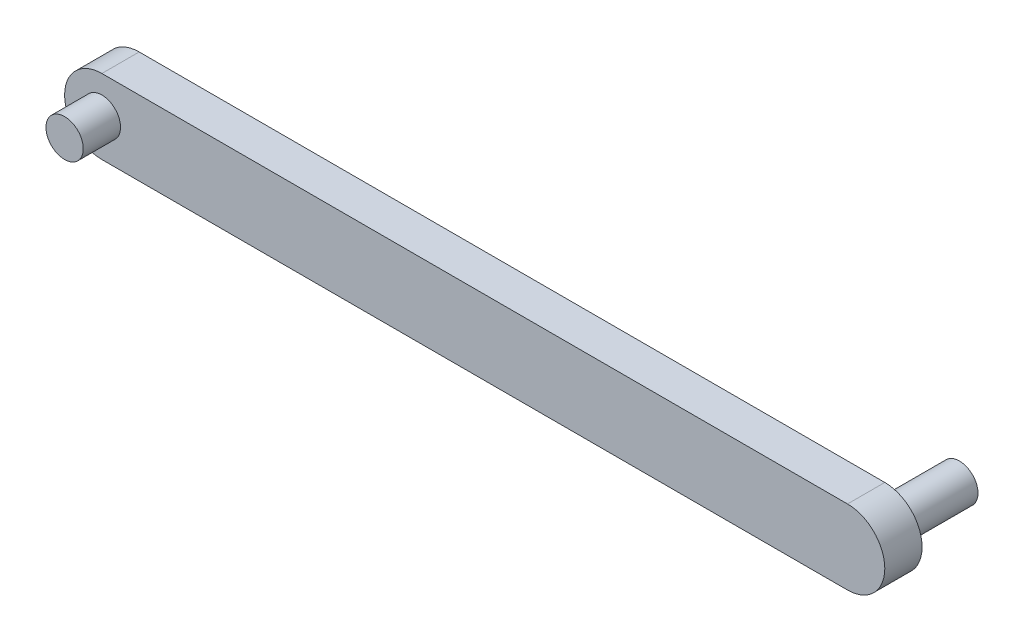
from build123d import *

# Parameters (mm, degrees)
EXTRUDE_1_DEPTH = 4
SKETCH_2_R      = 2
EXTRUDE_2_DEPTH = 8
SKETCH_3_R      = 2
EXTRUDE_3_DEPTH = 4


with BuildPart() as part:
    # 草图1 → 凸台-拉伸1 (new body)
    with BuildSketch(Plane.XY):
        with BuildLine():
            Line((-33.634370857, -4), (46.365629143, -4))
            ThreePointArc((46.365629143, -4), (50.365629143, 0), (46.365629143, 4))
            Line((46.365629143, 4), (-33.634370857, 4))
            ThreePointArc((-33.634370857, 4), (-37.634370857, 0), (-33.634370857, -4))
        make_face()
    extrude(amount=EXTRUDE_1_DEPTH)

    # 草图2 → 凸台-拉伸2 (add)
    with BuildSketch(Plane(origin=(0, 0, 0), x_dir=(-1, 0, 0), z_dir=(0, 0, -1))):
        with Locations((-46.365629143, 0)):
            Circle(SKETCH_2_R)
    extrude(amount=EXTRUDE_2_DEPTH)

    # 草图3 → 凸台-拉伸3 (add)
    with BuildSketch(Plane.XY.offset(4)):
        with Locations((-33.634370857, 0)):
            Circle(SKETCH_3_R)
    extrude(amount=EXTRUDE_3_DEPTH)


solid = part.part
